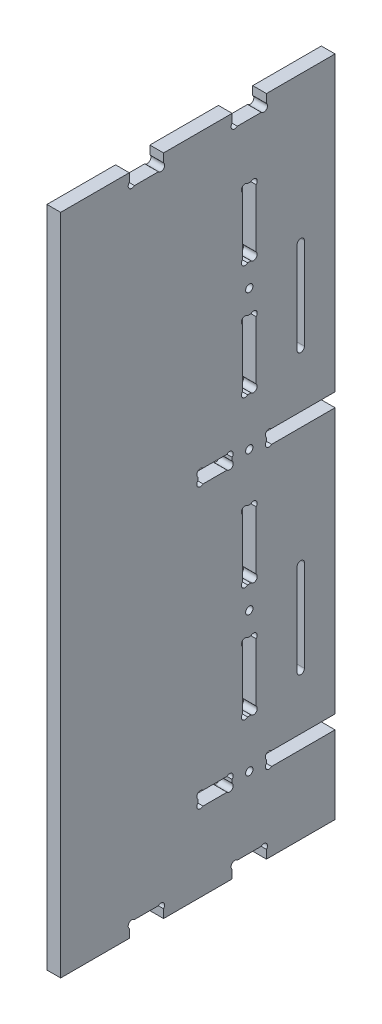
from build123d import *

# Parameters (mm, degrees)
ESQUISSE1_R             = 1.6
EXTRUSION1_DEPTH        = 6
ENL_V_MAT_EXTRU_1_DEPTH = 2.2


with BuildPart() as part:
    # Esquisse1 → Extrusion1 (new body)
    with BuildSketch(Plane(origin=(0, 0, 0), x_dir=(0, 0, -1), z_dir=(1, 0, 0))):
        with BuildLine():
            Line((32.2627417, 6), (42.7372583, 6))
            ThreePointArc((42.7372583, 6), (45, 6), (45, 3.7372583))
            Line((45, 3.7372583), (45, 0))
            Line((45, 0), (75, 0))
            Line((75, 0), (75, 3.7372583))
            ThreePointArc((75, 3.7372583), (75, 6), (77.2627417, 6))
            Line((77.2627417, 6), (87.7372583, 6))
            ThreePointArc((87.7372583, 6), (90, 6), (90, 3.7372583))
            Line((90, 3.7372583), (90, 0))
            Line((90, 0), (120, 0))
            Line((120, 0), (120, 34))
            Line((120, 34), (92.2627417, 34))
            ThreePointArc((92.2627417, 34), (90, 34), (90, 36.2627417))
            Line((90, 36.2627417), (90, 37.7372583))
            ThreePointArc((90, 37.7372583), (90, 40), (92.2627417, 40))
            Line((92.2627417, 40), (120, 40))
            Line((120, 40), (120, 156))
            Line((120, 156), (92.2627417, 156))
            ThreePointArc((92.2627417, 156), (90, 156), (90, 158.2627417))
            Line((90, 158.2627417), (90, 159.7372583))
            ThreePointArc((90, 159.7372583), (90, 162), (92.2627417, 162))
            Line((92.2627417, 162), (120, 162))
            Line((120, 162), (120, 290))
            Line((120, 290), (90, 290))
            Line((90, 290), (90, 286.2627417))
            ThreePointArc((90, 286.2627417), (90, 284), (87.7372583, 284))
            Line((87.7372583, 284), (77.2627417, 284))
            ThreePointArc((77.2627417, 284), (75, 284), (75, 286.2627417))
            Line((75, 286.2627417), (75, 290))
            Line((75, 290), (45, 290))
            Line((45, 290), (45, 286.2627417))
            ThreePointArc((45, 286.2627417), (45, 284), (42.7372583, 284))
            Line((42.7372583, 284), (32.2627417, 284))
            ThreePointArc((32.2627417, 284), (30, 284), (30, 286.2627417))
            Line((30, 286.2627417), (30, 290))
            Line((30, 290), (0, 290))
            Line((0, 290), (0, 0))
            Line((0, 0), (30, 0))
            Line((30, 0), (30, 3.7372583))
            ThreePointArc((30, 3.7372583), (30, 6), (32.2627417, 6))
        make_face()
        with Locations((82.5, 37)):
            Circle(ESQUISSE1_R, mode=Mode.SUBTRACT)
        with Locations(Location((82.5, 159, 0), (0, 0, 180))):  # turned: the seam where the file's is
            Circle(ESQUISSE1_R, mode=Mode.SUBTRACT)
        with Locations((82.5, 98)):
            Circle(ESQUISSE1_R, mode=Mode.SUBTRACT)
        with Locations(Location((82.5, 220, 0), (0, 0, 180))):  # turned: the seam where the file's is
            Circle(ESQUISSE1_R, mode=Mode.SUBTRACT)
        with BuildLine():
            Line((75, 37.7372583), (75, 36.2627417))
            ThreePointArc((75, 36.2627417), (75, 34), (72.7372583, 34))
            Line((72.7372583, 34), (62.2627417, 34))
            ThreePointArc((62.2627417, 34), (60, 34), (60, 36.2627417))
            Line((60, 36.2627417), (60, 37.7372583))
            ThreePointArc((60, 37.7372583), (60, 40), (62.2627417, 40))
            Line((62.2627417, 40), (72.7372583, 40))
            ThreePointArc((72.7372583, 40), (75, 40), (75, 37.7372583))
        make_face(mode=Mode.SUBTRACT)
        with BuildLine():
            Line((60, 158.2627417), (60, 159.7372583))
            ThreePointArc((60, 159.7372583), (60, 162), (62.2627417, 162))
            Line((62.2627417, 162), (72.7372583, 162))
            ThreePointArc((72.7372583, 162), (75, 162), (75, 159.7372583))
            Line((75, 159.7372583), (75, 158.2627417))
            ThreePointArc((75, 158.2627417), (75, 156), (72.7372583, 156))
            Line((72.7372583, 156), (62.2627417, 156))
            ThreePointArc((62.2627417, 156), (60, 156), (60, 158.2627417))
        make_face(mode=Mode.SUBTRACT)
        with BuildLine():
            Line((83.2372583, 138), (81.7627417, 138))
            ThreePointArc((81.7627417, 138), (79.5, 138), (79.5, 135.7372583))
            Line((79.5, 135.7372583), (79.5, 110.2627417))
            ThreePointArc((79.5, 110.2627417), (79.5, 108), (81.7627417, 108))
            Line((81.7627417, 108), (83.2372583, 108))
            ThreePointArc((83.2372583, 108), (85.5, 108), (85.5, 110.2627417))
            Line((85.5, 110.2627417), (85.5, 135.7372583))
            ThreePointArc((85.5, 135.7372583), (85.5, 138), (83.2372583, 138))
        make_face(mode=Mode.SUBTRACT)
        with BuildLine():
            Line((83.2372583, 58), (81.7627417, 58))
            ThreePointArc((81.7627417, 58), (79.5, 58), (79.5, 60.2627417))
            Line((79.5, 60.2627417), (79.5, 85.7372583))
            ThreePointArc((79.5, 85.7372583), (79.5, 88), (81.7627417, 88))
            Line((81.7627417, 88), (83.2372583, 88))
            ThreePointArc((83.2372583, 88), (85.5, 88), (85.5, 85.7372583))
            Line((85.5, 85.7372583), (85.5, 60.2627417))
            ThreePointArc((85.5, 60.2627417), (85.5, 58), (83.2372583, 58))
        make_face(mode=Mode.SUBTRACT)
        with BuildLine():
            Line((85.5, 257.7372583), (85.5, 232.2627417))
            ThreePointArc((85.5, 232.2627417), (85.5, 230), (83.2372583, 230))
            Line((83.2372583, 230), (81.7627417, 230))
            ThreePointArc((81.7627417, 230), (79.5, 230), (79.5, 232.2627417))
            Line((79.5, 232.2627417), (79.5, 257.7372583))
            ThreePointArc((79.5, 257.7372583), (79.5, 260), (81.7627417, 260))
            Line((81.7627417, 260), (83.2372583, 260))
            ThreePointArc((83.2372583, 260), (85.5, 260), (85.5, 257.7372583))
        make_face(mode=Mode.SUBTRACT)
        with BuildLine():
            Line((83.2372583, 210), (81.7627417, 210))
            ThreePointArc((81.7627417, 210), (79.5, 210), (79.5, 207.7372583))
            Line((79.5, 207.7372583), (79.5, 182.2627417))
            ThreePointArc((79.5, 182.2627417), (79.5, 180), (81.7627417, 180))
            Line((81.7627417, 180), (83.2372583, 180))
            ThreePointArc((83.2372583, 180), (85.5, 180), (85.5, 182.2627417))
            Line((85.5, 182.2627417), (85.5, 207.7372583))
            ThreePointArc((85.5, 207.7372583), (85.5, 210), (83.2372583, 210))
        make_face(mode=Mode.SUBTRACT)
        with BuildLine():
            Line((106.6, 104), (106.6, 64))
            ThreePointArc((106.6, 64), (105, 62.4), (103.4, 64))
            Line((103.4, 64), (103.4, 104))
            ThreePointArc((103.4, 104), (105, 105.6), (106.6, 104))
        make_face(mode=Mode.SUBTRACT)
        with BuildLine():
            Line((106.6, 226), (106.6, 186))
            ThreePointArc((106.6, 186), (105, 184.4), (103.4, 186))
            Line((103.4, 186), (103.4, 226))
            ThreePointArc((103.4, 226), (105, 227.6), (106.6, 226))
        make_face(mode=Mode.SUBTRACT)
    extrude(amount=EXTRUSION1_DEPTH)

    # Esquisse2 → Enlèv. mat.-Extru.1 (cut)
    with BuildSketch(Plane.ZY):
        with BuildLine():
            Line((-117.55, 123), (-117.55, 45))
            ThreePointArc((-117.55, 45), (-116, 43.45), (-114.45, 45))
            Line((-114.45, 45), (-114.45, 123))
            ThreePointArc((-114.45, 123), (-116, 124.55), (-117.55, 123))
        make_face()
        with BuildLine():
            Line((-95.55, 45), (-95.55, 123))
            ThreePointArc((-95.55, 123), (-94, 124.55), (-92.45, 123))
            Line((-92.45, 123), (-92.45, 45))
            ThreePointArc((-92.45, 45), (-94, 43.45), (-95.55, 45))
        make_face()
        with BuildLine():
            Line((-117.55, 245), (-117.55, 167))
            ThreePointArc((-117.55, 167), (-116, 165.45), (-114.45, 167))
            Line((-114.45, 167), (-114.45, 245))
            ThreePointArc((-114.45, 245), (-116, 246.55), (-117.55, 245))
        make_face()
        with BuildLine():
            Line((-95.55, 167), (-95.55, 245))
            ThreePointArc((-95.55, 245), (-94, 246.55), (-92.45, 245))
            Line((-92.45, 245), (-92.45, 167))
            ThreePointArc((-92.45, 167), (-94, 165.45), (-95.55, 167))
        make_face()
    extrude(amount=-ENL_V_MAT_EXTRU_1_DEPTH, mode=Mode.SUBTRACT)


solid = part.part
